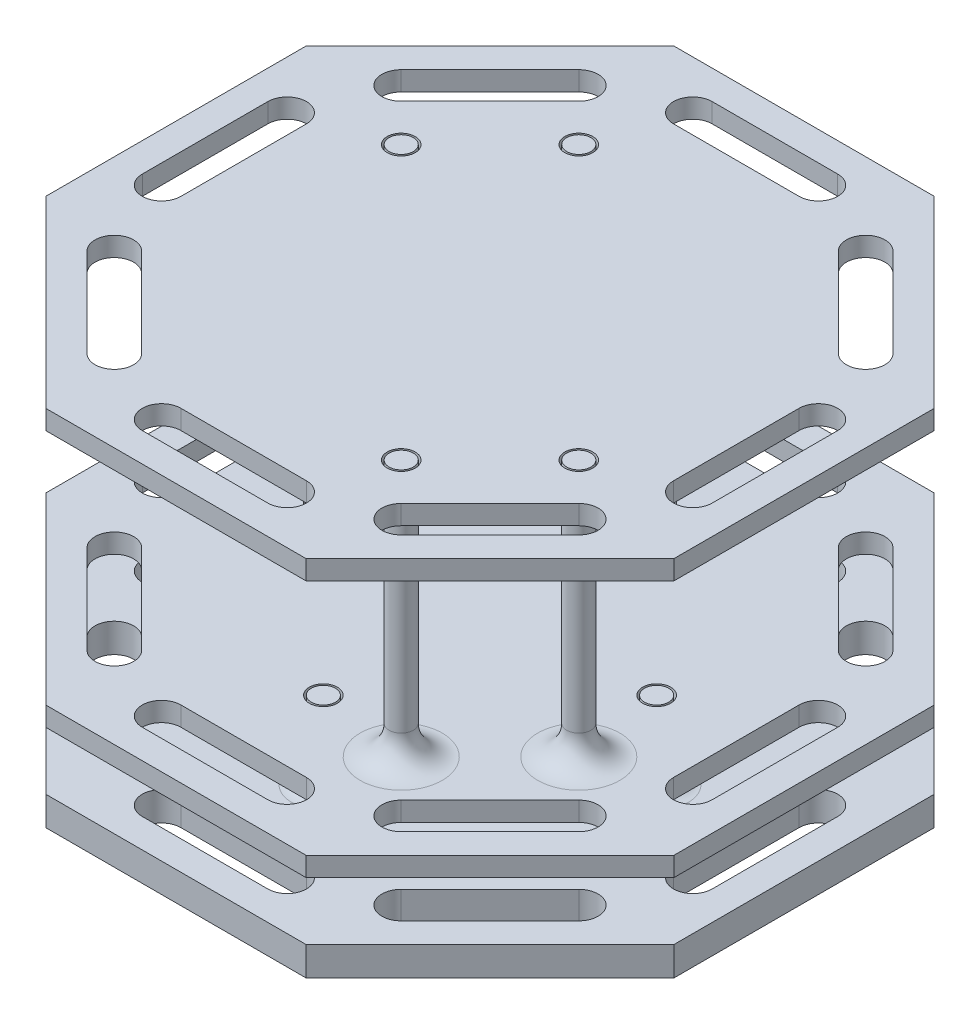
from build123d import *

# Parameters (mm, degrees)
SKETCH1_R           = 1.5
BOSS_EXTRUDE1_DEPTH = 3.81
SKETCH2_R           = 1.5875
BOSS_EXTRUDE2_DEPTH = 10.16
FILLET1_R           = 2.54
SKETCH3_R           = 1.8415
BOSS_EXTRUDE3_DEPTH = 2.54
SKETCH4_R           = 1.5875
BOSS_EXTRUDE4_DEPTH = 33.782
FILLET2_R           = 3.81
SKETCH5_R           = 1.8415
BOSS_EXTRUDE5_DEPTH = 2.54


with BuildPart() as part:
    # Sketch1 → Boss-Extrude1 (new body)
    with BuildSketch(Plane(origin=(0, 0, 0), x_dir=(1, 0, 0), z_dir=(0, 1, 0))):
        Polygon((41.275, 17.096664787), (17.096664787, 41.275), (-17.096664787, 41.275), (-41.275, 17.096664787), (-41.275, -17.096664787), (-17.096664787, -41.275), (17.096664787, -41.275), (41.275, -17.096664787), align=None)
        with Locations((-17.78, 5.969)):
            Circle(SKETCH1_R, mode=Mode.SUBTRACT)
        with Locations((-17.78, -5.969)):
            Circle(SKETCH1_R, mode=Mode.SUBTRACT)
        with Locations((5.969, 17.78)):
            Circle(SKETCH1_R, mode=Mode.SUBTRACT)
        with Locations((-5.969, 17.78)):
            Circle(SKETCH1_R, mode=Mode.SUBTRACT)
        with Locations((17.78, -5.969)):
            Circle(SKETCH1_R, mode=Mode.SUBTRACT)
        with Locations((17.78, 5.969)):
            Circle(SKETCH1_R, mode=Mode.SUBTRACT)
        with Locations((-5.969, -17.78)):
            Circle(SKETCH1_R, mode=Mode.SUBTRACT)
        with Locations((5.969, -17.78)):
            Circle(SKETCH1_R, mode=Mode.SUBTRACT)
        with BuildLine():
            Line((-8.255, 37.465), (8.255, 37.465))
            ThreePointArc((8.255, 37.465), (10.795, 34.925), (8.255, 32.385))
            Line((8.255, 32.385), (-8.255, 32.385))
            ThreePointArc((-8.255, 32.385), (-10.795, 34.925), (-8.255, 37.465))
        make_face(mode=Mode.SUBTRACT)
        with BuildLine():
            Line((17.06248663, 28.736819587), (28.736819587, 17.06248663))
            ThreePointArc((28.736819587, 17.06248663), (32.328922036, 17.06248663), (32.328922036, 20.654589078))
            Line((32.328922036, 20.654589078), (20.654589078, 32.328922036))
            ThreePointArc((20.654589078, 32.328922036), (17.06248663, 32.328922036), (17.06248663, 28.736819587))
        make_face(mode=Mode.SUBTRACT)
        with BuildLine():
            Line((32.385, 8.255), (32.385, -8.255))
            ThreePointArc((32.385, -8.255), (34.925, -10.795), (37.465, -8.255))
            Line((37.465, -8.255), (37.465, 8.255))
            ThreePointArc((37.465, 8.255), (34.925, 10.795), (32.385, 8.255))
        make_face(mode=Mode.SUBTRACT)
        with BuildLine():
            Line((28.736819587, -17.06248663), (17.06248663, -28.736819587))
            ThreePointArc((17.06248663, -28.736819587), (17.06248663, -32.328922036), (20.654589078, -32.328922036))
            Line((20.654589078, -32.328922036), (32.328922036, -20.654589078))
            ThreePointArc((32.328922036, -20.654589078), (32.328922036, -17.06248663), (28.736819587, -17.06248663))
        make_face(mode=Mode.SUBTRACT)
        with BuildLine():
            Line((8.255, -32.385), (-8.255, -32.385))
            ThreePointArc((-8.255, -32.385), (-10.795, -34.925), (-8.255, -37.465))
            Line((-8.255, -37.465), (8.255, -37.465))
            ThreePointArc((8.255, -37.465), (10.795, -34.925), (8.255, -32.385))
        make_face(mode=Mode.SUBTRACT)
        with BuildLine():
            Line((-17.06248663, -28.736819587), (-28.736819587, -17.06248663))
            ThreePointArc((-28.736819587, -17.06248663), (-32.328922036, -17.06248663), (-32.328922036, -20.654589078))
            Line((-32.328922036, -20.654589078), (-20.654589078, -32.328922036))
            ThreePointArc((-20.654589078, -32.328922036), (-17.06248663, -32.328922036), (-17.06248663, -28.736819587))
        make_face(mode=Mode.SUBTRACT)
        with BuildLine():
            Line((-32.385, -8.255), (-32.385, 8.255))
            ThreePointArc((-32.385, 8.255), (-34.925, 10.795), (-37.465, 8.255))
            Line((-37.465, 8.255), (-37.465, -8.255))
            ThreePointArc((-37.465, -8.255), (-34.925, -10.795), (-32.385, -8.255))
        make_face(mode=Mode.SUBTRACT)
        with BuildLine():
            Line((-28.736819587, 17.06248663), (-17.06248663, 28.736819587))
            ThreePointArc((-17.06248663, 28.736819587), (-17.06248663, 32.328922036), (-20.654589078, 32.328922036))
            Line((-20.654589078, 32.328922036), (-32.328922036, 20.654589078))
            ThreePointArc((-32.328922036, 20.654589078), (-32.328922036, 17.06248663), (-28.736819587, 17.06248663))
        make_face(mode=Mode.SUBTRACT)
    extrude(amount=BOSS_EXTRUDE1_DEPTH)

    # Sketch2 → Boss-Extrude2 (add)
    with BuildSketch(Plane(origin=(0, 3.81, 0), x_dir=(1, 0, 0), z_dir=(0, 1, 0))):
        with Locations((-21.911824935, 0)):
            Circle(SKETCH2_R)
        with Locations((21.911824935, 0)):
            Circle(SKETCH2_R)
        with Locations((0, 21.911824935)):
            Circle(SKETCH2_R)
        with Locations((0, -21.911824935)):
            Circle(SKETCH2_R)
    extrude(amount=BOSS_EXTRUDE2_DEPTH)

    # Fillet1
    fillet1_edges = [part.edges().sort_by_distance(p)[0] for p in [
        (-23.499324935, 3.81, 0),
        (20.324324935, 3.81, 0),
        (-1.5875, 3.81, -21.911824935),
        (-1.5875, 3.81, 21.911824935),
    ]]
    fillet(fillet1_edges, radius=FILLET1_R)


with BuildPart() as body_2:
    # Sketch3 → Boss-Extrude3 (new body)
    with BuildSketch(Plane(origin=(0, 13.97, 0), x_dir=(1, 0, 0), z_dir=(0, 1, 0))):
        Polygon((41.275, -17.096664787), (41.275, 17.096664787), (17.096664787, 41.275), (-17.096664787, 41.275), (-41.275, 17.096664787), (-41.275, -17.096664787), (-17.096664787, -41.275), (17.096664787, -41.275), align=None)
        with Locations((0, 21.911824935)):
            Circle(SKETCH3_R, mode=Mode.SUBTRACT)
        with Locations((-21.911824935, 0)):
            Circle(SKETCH3_R, mode=Mode.SUBTRACT)
        with Locations((0, -21.911824935)):
            Circle(SKETCH3_R, mode=Mode.SUBTRACT)
        with Locations((21.911824935, 0)):
            Circle(SKETCH3_R, mode=Mode.SUBTRACT)
        with BuildLine():
            Line((-37.465, 8.255), (-37.465, -8.255))
            ThreePointArc((-37.465, -8.255), (-34.925, -10.795), (-32.385, -8.255))
            Line((-32.385, -8.255), (-32.385, 8.255))
            ThreePointArc((-32.385, 8.255), (-34.925, 10.795), (-37.465, 8.255))
        make_face(mode=Mode.SUBTRACT)
        with BuildLine():
            Line((-32.328922036, -20.654589078), (-20.654589078, -32.328922036))
            ThreePointArc((-20.654589078, -32.328922036), (-17.06248663, -32.328922036), (-17.06248663, -28.736819587))
            Line((-17.06248663, -28.736819587), (-28.736819587, -17.06248663))
            ThreePointArc((-28.736819587, -17.06248663), (-32.328922036, -17.06248663), (-32.328922036, -20.654589078))
        make_face(mode=Mode.SUBTRACT)
        with BuildLine():
            Line((-8.255, -37.465), (8.255, -37.465))
            ThreePointArc((8.255, -37.465), (10.795, -34.925), (8.255, -32.385))
            Line((8.255, -32.385), (-8.255, -32.385))
            ThreePointArc((-8.255, -32.385), (-10.795, -34.925), (-8.255, -37.465))
        make_face(mode=Mode.SUBTRACT)
        with BuildLine():
            Line((20.654589078, -32.328922036), (32.328922036, -20.654589078))
            ThreePointArc((32.328922036, -20.654589078), (32.328922036, -17.06248663), (28.736819587, -17.06248663))
            Line((28.736819587, -17.06248663), (17.06248663, -28.736819587))
            ThreePointArc((17.06248663, -28.736819587), (17.06248663, -32.328922036), (20.654589078, -32.328922036))
        make_face(mode=Mode.SUBTRACT)
        with BuildLine():
            Line((37.465, -8.255), (37.465, 8.255))
            ThreePointArc((37.465, 8.255), (34.925, 10.795), (32.385, 8.255))
            Line((32.385, 8.255), (32.385, -8.255))
            ThreePointArc((32.385, -8.255), (34.925, -10.795), (37.465, -8.255))
        make_face(mode=Mode.SUBTRACT)
        with BuildLine():
            Line((17.06248663, 28.736819587), (28.736819587, 17.06248663))
            ThreePointArc((28.736819587, 17.06248663), (32.328922036, 17.06248663), (32.328922036, 20.654589078))
            Line((32.328922036, 20.654589078), (20.654589078, 32.328922036))
            ThreePointArc((20.654589078, 32.328922036), (17.06248663, 32.328922036), (17.06248663, 28.736819587))
        make_face(mode=Mode.SUBTRACT)
        with BuildLine():
            Line((-8.255, 32.385), (8.255, 32.385))
            ThreePointArc((8.255, 32.385), (10.795, 34.925), (8.255, 37.465))
            Line((8.255, 37.465), (-8.255, 37.465))
            ThreePointArc((-8.255, 37.465), (-10.795, 34.925), (-8.255, 32.385))
        make_face(mode=Mode.SUBTRACT)
        with BuildLine():
            Line((-20.654589078, 32.328922036), (-32.328922036, 20.654589078))
            ThreePointArc((-32.328922036, 20.654589078), (-32.328922036, 17.06248663), (-28.736819587, 17.06248663))
            Line((-28.736819587, 17.06248663), (-17.06248663, 28.736819587))
            ThreePointArc((-17.06248663, 28.736819587), (-17.06248663, 32.328922036), (-20.654589078, 32.328922036))
        make_face(mode=Mode.SUBTRACT)
    extrude(amount=-BOSS_EXTRUDE3_DEPTH)

    # Sketch4 → Boss-Extrude4 (add)
    with BuildSketch(Plane(origin=(0, 13.97, 0), x_dir=(1, 0, 0), z_dir=(0, 1, 0))):
        with Locations((-23.797678721, 12.123345763)):
            Circle(SKETCH4_R)
        with Locations((-12.123345763, 23.797678721)):
            Circle(SKETCH4_R)
        with Locations((23.797678721, -12.123345763)):
            Circle(SKETCH4_R)
        with Locations((12.123345763, -23.797678721)):
            Circle(SKETCH4_R)
    extrude(amount=BOSS_EXTRUDE4_DEPTH)

    # Fillet2
    fillet2_edges = [body_2.edges().sort_by_distance(p)[0] for p in [
        (-25.385178721, 13.97, -12.123345763),
        (-13.710845763, 13.97, -23.797678721),
        (22.210178721, 13.97, 12.123345763),
        (10.535845763, 13.97, 23.797678721),
    ]]
    fillet(fillet2_edges, radius=FILLET2_R)


with BuildPart() as body_3:
    # Sketch5 → Boss-Extrude5 (new body)
    with BuildSketch(Plane(origin=(0, 47.752, 0), x_dir=(1, 0, 0), z_dir=(0, 1, 0))):
        Polygon((-17.096664787, -41.275), (17.096664787, -41.275), (41.275, -17.096664787), (41.275, 17.096664787), (17.096664787, 41.275), (-17.096664787, 41.275), (-41.275, 17.096664787), (-41.275, -17.096664787), align=None)
        with Locations((-12.123345763, 23.797678721)):
            Circle(SKETCH5_R, mode=Mode.SUBTRACT)
        with Locations((-23.797678721, 12.123345763)):
            Circle(SKETCH5_R, mode=Mode.SUBTRACT)
        with Locations((23.797678721, -12.123345763)):
            Circle(SKETCH5_R, mode=Mode.SUBTRACT)
        with Locations((12.123345763, -23.797678721)):
            Circle(SKETCH5_R, mode=Mode.SUBTRACT)
        with BuildLine():
            Line((-28.736819587, 17.06248663), (-17.06248663, 28.736819587))
            ThreePointArc((-17.06248663, 28.736819587), (-17.06248663, 32.328922036), (-20.654589078, 32.328922036))
            Line((-20.654589078, 32.328922036), (-32.328922036, 20.654589078))
            ThreePointArc((-32.328922036, 20.654589078), (-32.328922036, 17.06248663), (-28.736819587, 17.06248663))
        make_face(mode=Mode.SUBTRACT)
        with BuildLine():
            Line((-37.465, 8.255), (-37.465, -8.255))
            ThreePointArc((-37.465, -8.255), (-34.925, -10.795), (-32.385, -8.255))
            Line((-32.385, -8.255), (-32.385, 8.255))
            ThreePointArc((-32.385, 8.255), (-34.925, 10.795), (-37.465, 8.255))
        make_face(mode=Mode.SUBTRACT)
        with BuildLine():
            Line((-17.06248663, -28.736819587), (-28.736819587, -17.06248663))
            ThreePointArc((-28.736819587, -17.06248663), (-32.328922036, -17.06248663), (-32.328922036, -20.654589078))
            Line((-32.328922036, -20.654589078), (-20.654589078, -32.328922036))
            ThreePointArc((-20.654589078, -32.328922036), (-17.06248663, -32.328922036), (-17.06248663, -28.736819587))
        make_face(mode=Mode.SUBTRACT)
        with BuildLine():
            Line((-8.255, -37.465), (8.255, -37.465))
            ThreePointArc((8.255, -37.465), (10.795, -34.925), (8.255, -32.385))
            Line((8.255, -32.385), (-8.255, -32.385))
            ThreePointArc((-8.255, -32.385), (-10.795, -34.925), (-8.255, -37.465))
        make_face(mode=Mode.SUBTRACT)
        with BuildLine():
            Line((20.654589078, -32.328922036), (32.328922036, -20.654589078))
            ThreePointArc((32.328922036, -20.654589078), (32.328922036, -17.06248663), (28.736819587, -17.06248663))
            Line((28.736819587, -17.06248663), (17.06248663, -28.736819587))
            ThreePointArc((17.06248663, -28.736819587), (17.06248663, -32.328922036), (20.654589078, -32.328922036))
        make_face(mode=Mode.SUBTRACT)
        with BuildLine():
            Line((37.465, -8.255), (37.465, 8.255))
            ThreePointArc((37.465, 8.255), (34.925, 10.795), (32.385, 8.255))
            Line((32.385, 8.255), (32.385, -8.255))
            ThreePointArc((32.385, -8.255), (34.925, -10.795), (37.465, -8.255))
        make_face(mode=Mode.SUBTRACT)
        with BuildLine():
            Line((17.06248663, 28.736819587), (28.736819587, 17.06248663))
            ThreePointArc((28.736819587, 17.06248663), (32.328922036, 17.06248663), (32.328922036, 20.654589078))
            Line((32.328922036, 20.654589078), (20.654589078, 32.328922036))
            ThreePointArc((20.654589078, 32.328922036), (17.06248663, 32.328922036), (17.06248663, 28.736819587))
        make_face(mode=Mode.SUBTRACT)
        with BuildLine():
            Line((-8.255, 32.385), (8.255, 32.385))
            ThreePointArc((8.255, 32.385), (10.795, 34.925), (8.255, 37.465))
            Line((8.255, 37.465), (-8.255, 37.465))
            ThreePointArc((-8.255, 37.465), (-10.795, 34.925), (-8.255, 32.385))
        make_face(mode=Mode.SUBTRACT)
    extrude(amount=-BOSS_EXTRUDE5_DEPTH)


solid = Compound([part.part, body_2.part, body_3.part])
